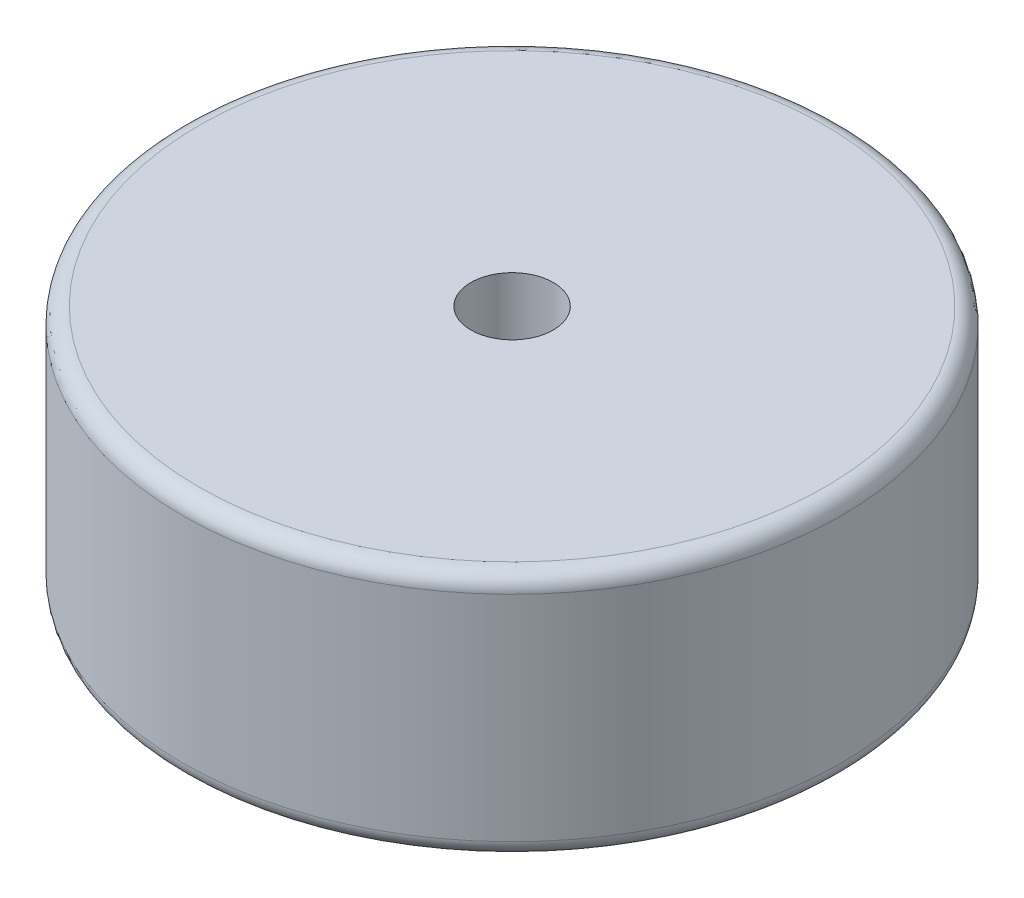
from build123d import *

# Parameters (mm, degrees)
SKETCH1_R           = 2
SKETCH1_R_2         = 0.25
BOSS_EXTRUDE1_DEPTH = 1.5
FILLET1_R           = 0.1


with BuildPart() as part:
    # Sketch1 → Boss-Extrude1 (new body)
    with BuildSketch(Plane(origin=(0, 0, 0), x_dir=(1, 0, 0), z_dir=(0, 1, 0))):
        Circle(SKETCH1_R)
        Circle(SKETCH1_R_2, mode=Mode.SUBTRACT)
    extrude(amount=BOSS_EXTRUDE1_DEPTH)

    # Fillet1
    fillet1_edges = [part.edges().sort_by_distance(p)[0] for p in [
        (-2, 0, 0),
        (-2, 1.5, 0),
    ]]
    fillet(fillet1_edges, radius=FILLET1_R)


solid = part.part
